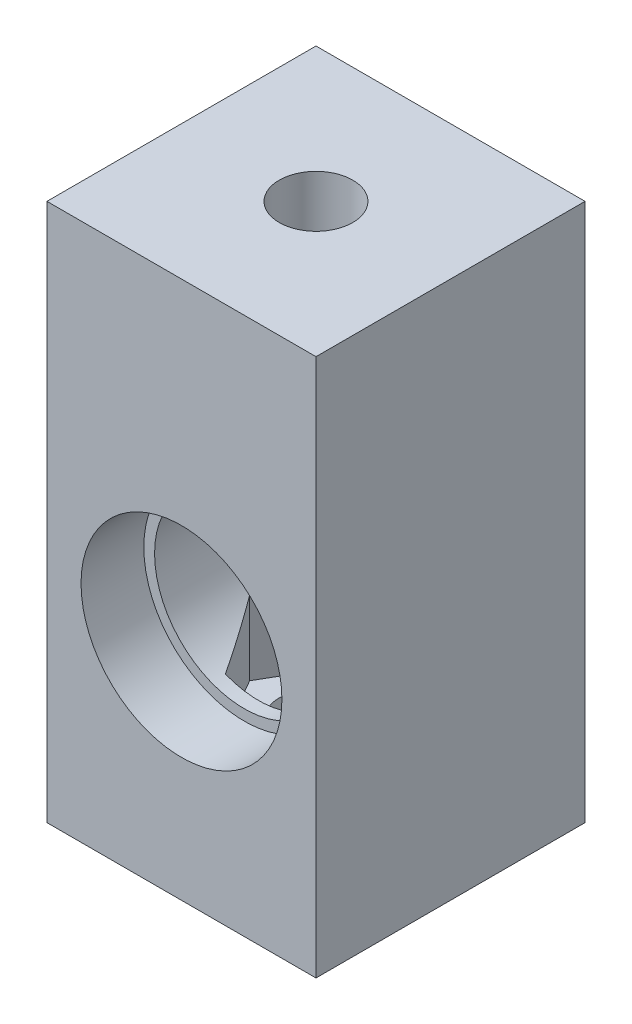
from build123d import *

# Parameters (mm, degrees)
SKETCH1_W           = 30
SKETCH1_H           = 30
BOSS_EXTRUDE1_DEPTH = 50
SKETCH2_R           = 10
CUT_EXTRUDE1_DEPTH  = 31
SKETCH3_R           = 11.2
CUT_EXTRUDE2_DEPTH  = 7
SKETCH4_W           = 30
SKETCH4_H           = 30
BOSS_EXTRUDE2_DEPTH = 10
SKETCH5_R           = 4.1
CUT_EXTRUDE3_DEPTH  = 61
CUT_EXTRUDE4_START  = -20
CUT_EXTRUDE4_DEPTH  = 30


with BuildPart() as part:
    # Sketch1 → Boss-Extrude1 (new body)
    with BuildSketch(Plane(origin=(0, 0, 0), x_dir=(1, 0, 0), z_dir=(0, 1, 0))):
        Rectangle(SKETCH1_W, SKETCH1_H)
    extrude(amount=BOSS_EXTRUDE1_DEPTH)

    # Sketch2 → Cut-Extrude1 (cut, through all)
    with BuildSketch(Plane.XY.offset(15)):
        with Locations((0, 25)):
            Circle(SKETCH2_R)
    extrude(amount=-CUT_EXTRUDE1_DEPTH, mode=Mode.SUBTRACT)

    # Sketch3 → Cut-Extrude2 (cut)
    with BuildSketch(Plane.XY.offset(15)):
        with Locations((0, 25)):
            Circle(SKETCH3_R)
    extrude(amount=-CUT_EXTRUDE2_DEPTH, mode=Mode.SUBTRACT)

    # Sketch4 → Boss-Extrude2 (add)
    with BuildSketch(Plane(origin=(0, 50, 0), x_dir=(1, 0, 0), z_dir=(0, 1, 0))):
        Rectangle(SKETCH4_W, SKETCH4_H)
    extrude(amount=BOSS_EXTRUDE2_DEPTH)

    # Sketch5 → Cut-Extrude3 (cut, through all)
    with BuildSketch(Plane(origin=(0, 60, 0), x_dir=(1, 0, 0), z_dir=(0, 1, 0))):
        with Locations(Location((0, 0, 0), (0, 0, 270))):  # turned: the seam where the file's is
            Circle(SKETCH5_R)
    extrude(amount=-CUT_EXTRUDE3_DEPTH, mode=Mode.SUBTRACT)

    # Sketch6 → Cut-Extrude4 (cut)
    with BuildSketch(Plane(origin=(0, 60, 0), x_dir=(1, 0, 0), z_dir=(0, 1, 0)).offset(CUT_EXTRUDE4_START)):
        Polygon((-3.7, 6.408587988), (-7.4, 0), (-3.7, -6.408587988), (3.7, -6.408587988), (7.4, 0), (3.7, 6.408587988), align=None)
    extrude(amount=-CUT_EXTRUDE4_DEPTH, mode=Mode.SUBTRACT)


solid = part.part
